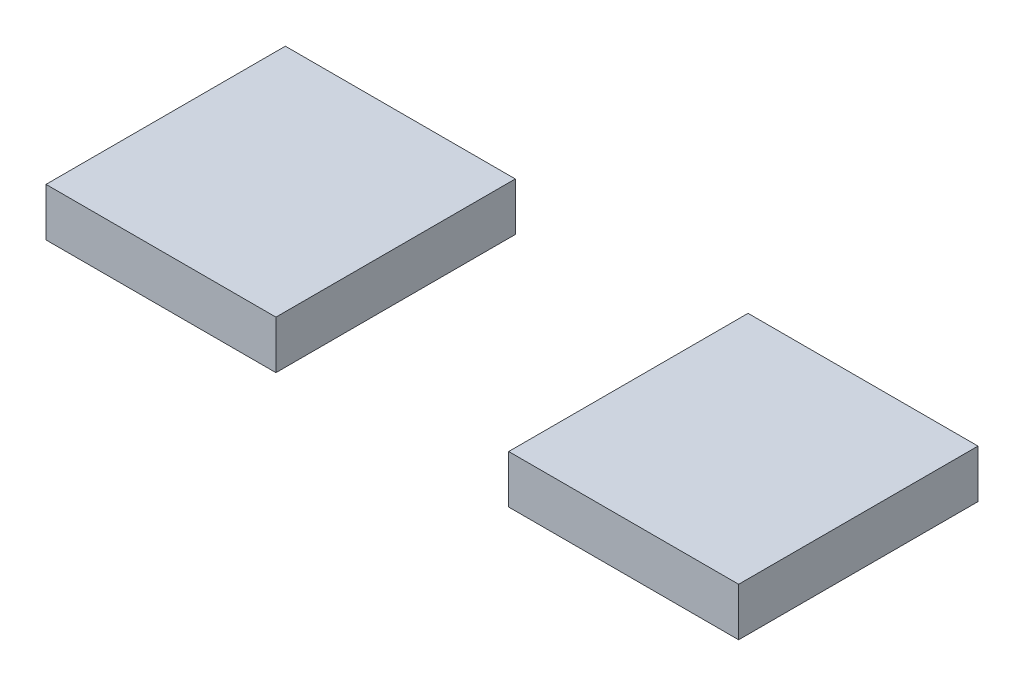
from build123d import *

# Parameters (mm, degrees)
SKIZZE1_W                       = 32.493442011
SKIZZE1_H                       = 33.825140454
AUFSATZ_LINEAR_AUSTRAGEN1_DEPTH = 6.8
KREISMUSTER1_COUNT              = 2


with BuildPart() as part:
    # Skizze1 → Aufsatz-Linear austragen1 (new body)
    with BuildSketch(Plane(origin=(0, 0, 0), x_dir=(1, 0, 0), z_dir=(0, 1, 0))):
        with Locations((-69.435959861, 0)):
            Rectangle(SKIZZE1_W, SKIZZE1_H)
    extrude(amount=AUFSATZ_LINEAR_AUSTRAGEN1_DEPTH)


with BuildPart() as kreismuster1_1:
    # Kreismuster1: pattern copy
    add(part.part.rotate(Axis((-36.7427755, 0, 0), (0, 1, 0)), 1 * 360 / KREISMUSTER1_COUNT))


solid = Compound([part.part, kreismuster1_1.part])
